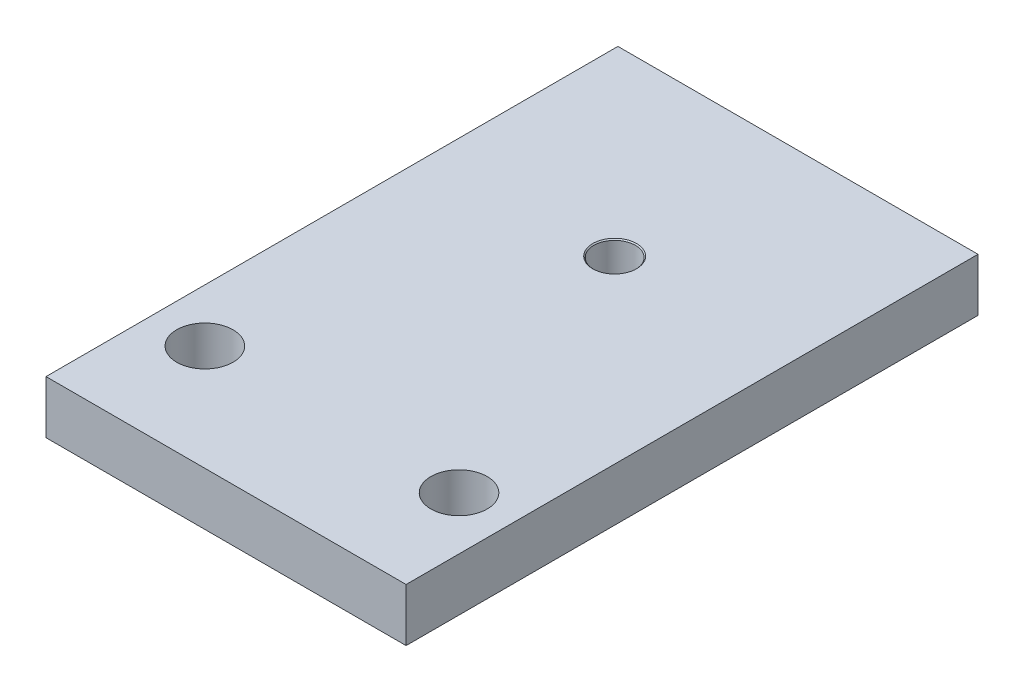
from build123d import *

# Parameters (mm, degrees)
SKETCH1_W               = 43.18
SKETCH1_H               = 68.58
BOSS_EXTRUDE1_DEPTH     = 6.35
F_1_4_CLEARANCE_HOLE1_D = 6.7564
SKETCH7_R               = 2.5
CUT_EXTRUDE1_DEPTH      = 7.35
CHAMFER1_SIZE           = 0.127


with BuildPart() as part:
    # Sketch1 → Boss-Extrude1 (new body)
    with BuildSketch(Plane(origin=(0, 0, 0), x_dir=(1, 0, 0), z_dir=(0, 1, 0))):
        Rectangle(SKETCH1_W, SKETCH1_H)
    extrude(amount=BOSS_EXTRUDE1_DEPTH)

    # 1/4 Clearance Hole1 (through all)
    with Locations(Plane(origin=(0, 6.35, 0), x_dir=(1, 0, 0), z_dir=(0, 1, 0))):
        with Locations((15.24, -21.59), (-15.24, -21.59)):
            Hole(F_1_4_CLEARANCE_HOLE1_D / 2)

    # Sketch7 → Cut-Extrude1 (cut, through all)
    with BuildSketch(Plane.XZ):
        with Locations((0, -12.31)):
            Circle(SKETCH7_R)
    extrude(amount=-CUT_EXTRUDE1_DEPTH, mode=Mode.SUBTRACT)

    # Chamfer1
    chamfer1_edges = [part.edges().sort_by_distance(p)[0] for p in [
        (-2.5, 6.35, -12.31),
        (-2.5, 0, -12.31),
    ]]
    chamfer(chamfer1_edges, length=CHAMFER1_SIZE)


solid = part.part
